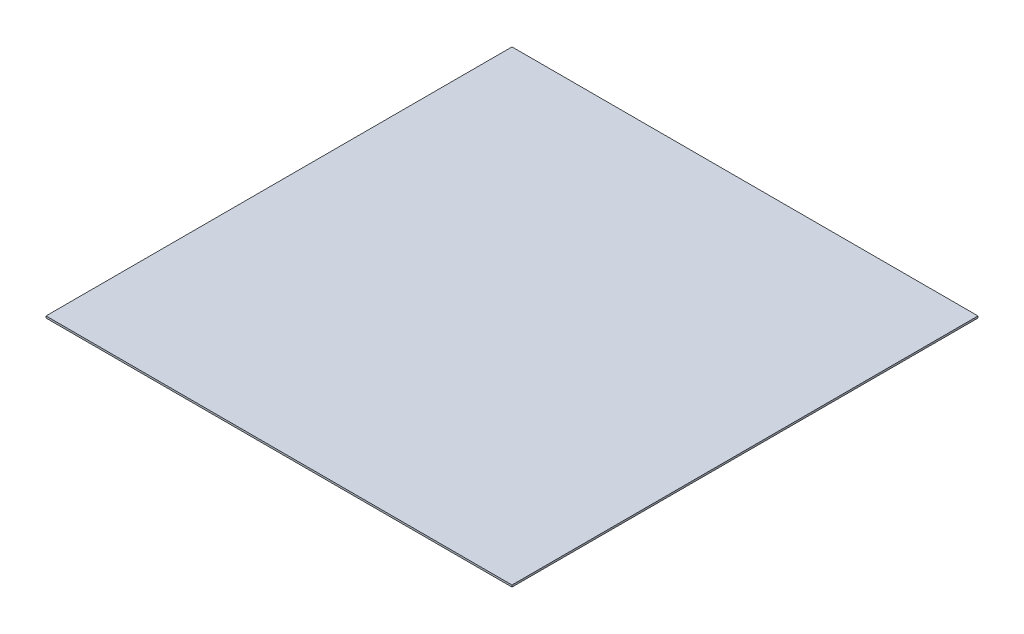
from build123d import *

# Parameters (mm, degrees)
SKETCH1_R               = 75
BOSS_EXTRUDE1_DEPTH     = 10
SKETCH2_R               = 45
SKETCH2_R_2             = 40
BOSS_EXTRUDE2_DEPTH     = 50
SKETCH5_W               = 75
SKETCH5_H               = 75
BOSS_EXTRUDE3_DEPTH     = 50
CUT_EXTRUDE2_DEPTH      = 103
CUT_EXTRUDE3_DEPTH      = 103
CUT_EXTRUDE3_DEPTH_BACK = 103
CUT_EXTRUDE4_DEPTH      = 103
CUT_EXTRUDE4_DEPTH_BACK = 103
SKETCH9_W               = 20
SKETCH9_H               = 50
SKETCH10_R              = 5
CUT_EXTRUDE5_DEPTH      = 103
SKETCH11_R              = 5
SKETCH13_W              = 1000
SKETCH13_H              = 1000
BOSS_EXTRUDE4_DEPTH     = 4


with BuildPart() as part:
    # Sketch1 → Boss-Extrude1 (new body)
    with BuildSketch(Plane(origin=(0, 0, 0), x_dir=(1, 0, 0), z_dir=(0, 1, 0))):
        Circle(SKETCH1_R)
    extrude(amount=BOSS_EXTRUDE1_DEPTH)

    # Sketch2 → Boss-Extrude2 (add)
    with BuildSketch(Plane.XZ):
        Circle(SKETCH2_R)
        Circle(SKETCH2_R_2, mode=Mode.SUBTRACT)
    extrude(amount=BOSS_EXTRUDE2_DEPTH)

    # Sketch5 → Boss-Extrude3 (add)
    with BuildSketch(Plane(origin=(0, 10, 0), x_dir=(1, 0, 0), z_dir=(0, 1, 0))):
        Rectangle(SKETCH5_W, SKETCH5_H)
    extrude(amount=BOSS_EXTRUDE3_DEPTH)

    # Sketch6 → Cut-Extrude2 (cut)
    with BuildSketch(Plane.XY.offset(37.5)):
        Polygon((20, 60), (37.5, 10), (43.069722315, 10), (43.069722315, 63.034625831), (-42.678571429, 63.034625831), (-42.678571429, 10), (-37.5, 10), (-20, 60), align=None)
        Polygon((-12.90518995, 50), (-26.90518995, 10), (26.90518995, 10), (12.90518995, 50), align=None)
    extrude(amount=-CUT_EXTRUDE2_DEPTH, mode=Mode.SUBTRACT)

    # Sketch7 → Cut-Extrude3 (cut, two sides: drawn at the far end of the back side and taken through both)
    with BuildSketch(Plane(origin=(0, 0, 0), x_dir=(0, 0, -1), z_dir=(1, 0, 0)).offset(-CUT_EXTRUDE3_DEPTH_BACK)):
        Polygon((20, 60), (-20, 60), (-37.5, 10), (-47.69302584, 10), (-47.69302584, 63.764621125), (47.449694076, 63.764621125), (47.449694076, 10), (37.5, 10), align=None)
    extrude(amount=CUT_EXTRUDE3_DEPTH + CUT_EXTRUDE3_DEPTH_BACK, mode=Mode.SUBTRACT)

    # Sketch9 → Cut-Extrude4 (cut, two sides: drawn at the far end of the back side and taken through both)
    with BuildSketch(Plane(origin=(0, 0, 0), x_dir=(0, 0, -1), z_dir=(1, 0, 0)).offset(-CUT_EXTRUDE4_DEPTH_BACK)):
        with Locations((0, 35)):
            Rectangle(SKETCH9_W, SKETCH9_H)
    extrude(amount=CUT_EXTRUDE4_DEPTH + CUT_EXTRUDE4_DEPTH_BACK, mode=Mode.SUBTRACT)

    # Sketch10 → Cut-Extrude5 (cut)
    with BuildSketch(Plane(origin=(0, 10, 0), x_dir=(1, 0, 0), z_dir=(0, 1, 0))):
        Circle(SKETCH10_R)
    extrude(amount=-CUT_EXTRUDE5_DEPTH, mode=Mode.SUBTRACT)

    # Sweep1: sweep along a curve in space
    with BuildLine() as sweep1_path:
        Line((-60, 10, 0), (-60, 210, 0))
    # Sketch11 → Sweep1 (sweep)
    with BuildSketch(Plane(origin=(0, 10, 0), x_dir=(1, 0, 0), z_dir=(0, 1, 0))):
        with Locations((-60, 0)):
            Circle(SKETCH11_R)
        with Locations((30, 51.961524227)):
            Circle(SKETCH11_R)
        with Locations((30, -51.961524227)):
            Circle(SKETCH11_R)
    sweep(path=sweep1_path.line)

    # Sketch13 → Boss-Extrude4 (add)
    with BuildSketch(Plane(origin=(0, 210, 0), x_dir=(1, 0, 0), z_dir=(0, 1, 0))):
        Rectangle(SKETCH13_W, SKETCH13_H)
    extrude(amount=BOSS_EXTRUDE4_DEPTH)

    # Sketch17 → Revolve2 (revolve)
    with BuildSketch(Plane(origin=(0, 0, 0), x_dir=(0, 0, -1), z_dir=(1, 0, 0))):
        Polygon((10, 55), (10, 70), (5, 70), (3.237517532, 60.004465223), (-3.237517532, 60.004465223), (-5, 70), (-10, 70), (-10, 55), align=None)
    revolve(axis=Axis((0, 55, -10), (0, 0, 1)))


solid = part.part
